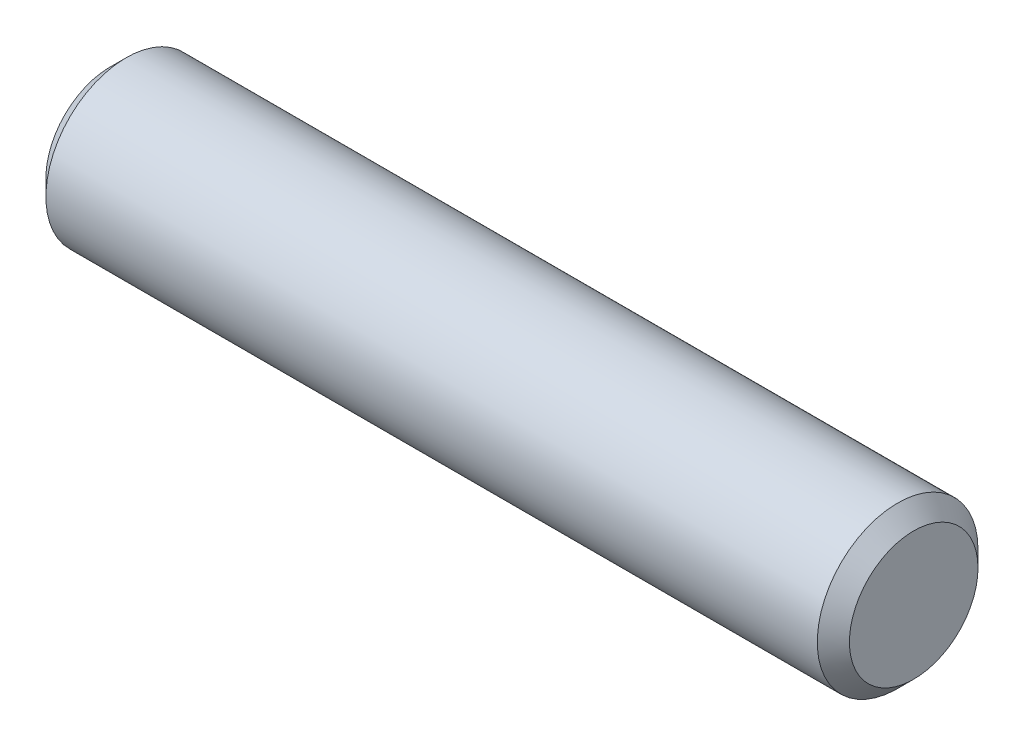
from build123d import *

# Parameters (mm, degrees)
SKETCH2_R           = 3.175
EXTRUDE1_DEPTH      = 15.875
EXTRUDE1_DEPTH_BACK = 15.875
CHAMFER1_SIZE       = 0.635


with BuildPart() as part:
    # Sketch2 → Extrude1 (new body, two sides)
    with BuildSketch(Plane(origin=(0, 0, 0), x_dir=(0, 0, -1), z_dir=(1, 0, 0))) as extrude1_sk:
        Circle(SKETCH2_R)
    extrude(amount=EXTRUDE1_DEPTH)
    extrude(extrude1_sk.sketch, amount=-EXTRUDE1_DEPTH_BACK)

    # Chamfer1
    chamfer1_edges = [part.edges().sort_by_distance(p)[0] for p in [
        (-15.875, 0, 3.175),
        (15.875, 0, 3.175),
    ]]
    chamfer(chamfer1_edges, length=CHAMFER1_SIZE)


solid = part.part
